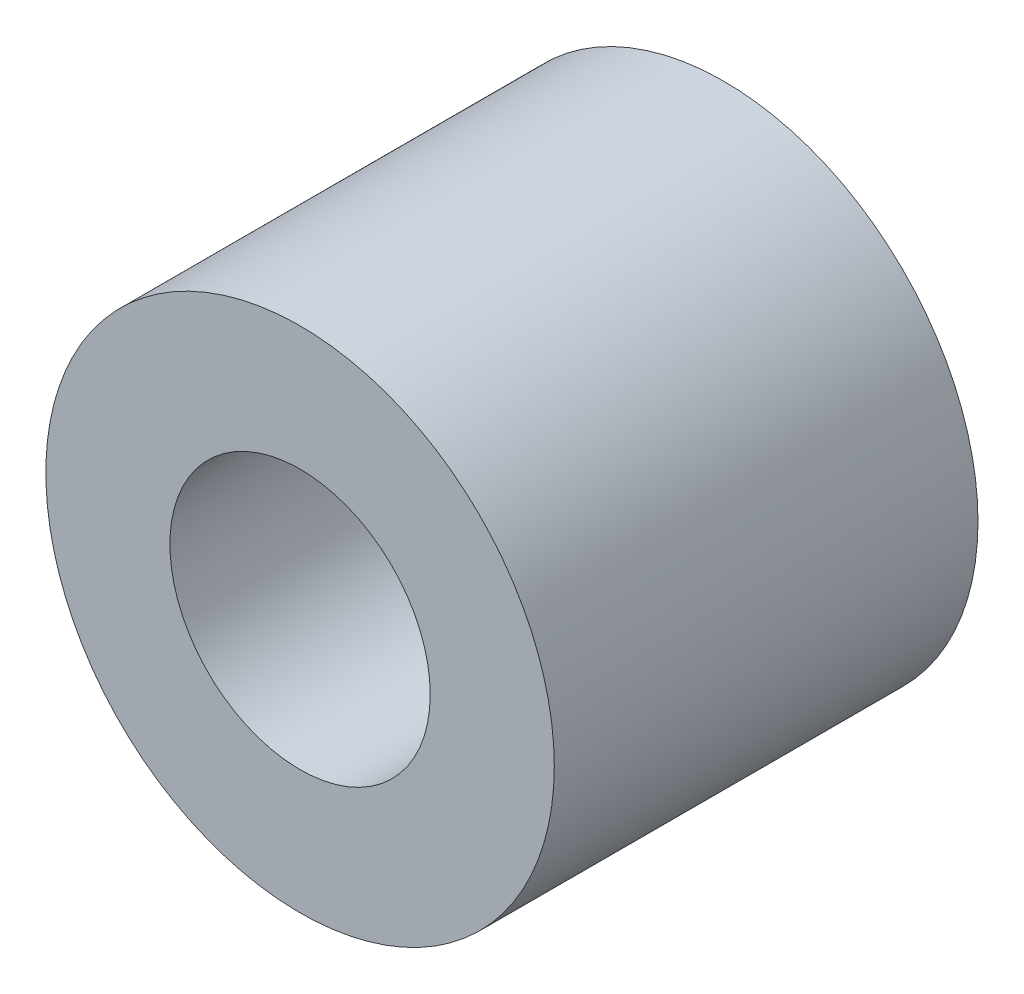
from build123d import *

# Parameters (mm, degrees)
SKETCH1_R           = 4.7625
SKETCH1_R_2         = 2.4384
EXTRUDE1_DEPTH      = 3.96875
EXTRUDE1_DEPTH_BACK = 3.96875


with BuildPart() as part:
    # Sketch1 → Extrude1 (new body, two sides)
    with BuildSketch(Plane.XY) as extrude1_sk:
        Circle(SKETCH1_R)
        Circle(SKETCH1_R_2, mode=Mode.SUBTRACT)
    extrude(amount=EXTRUDE1_DEPTH)
    extrude(extrude1_sk.sketch, amount=-EXTRUDE1_DEPTH_BACK)


solid = part.part
